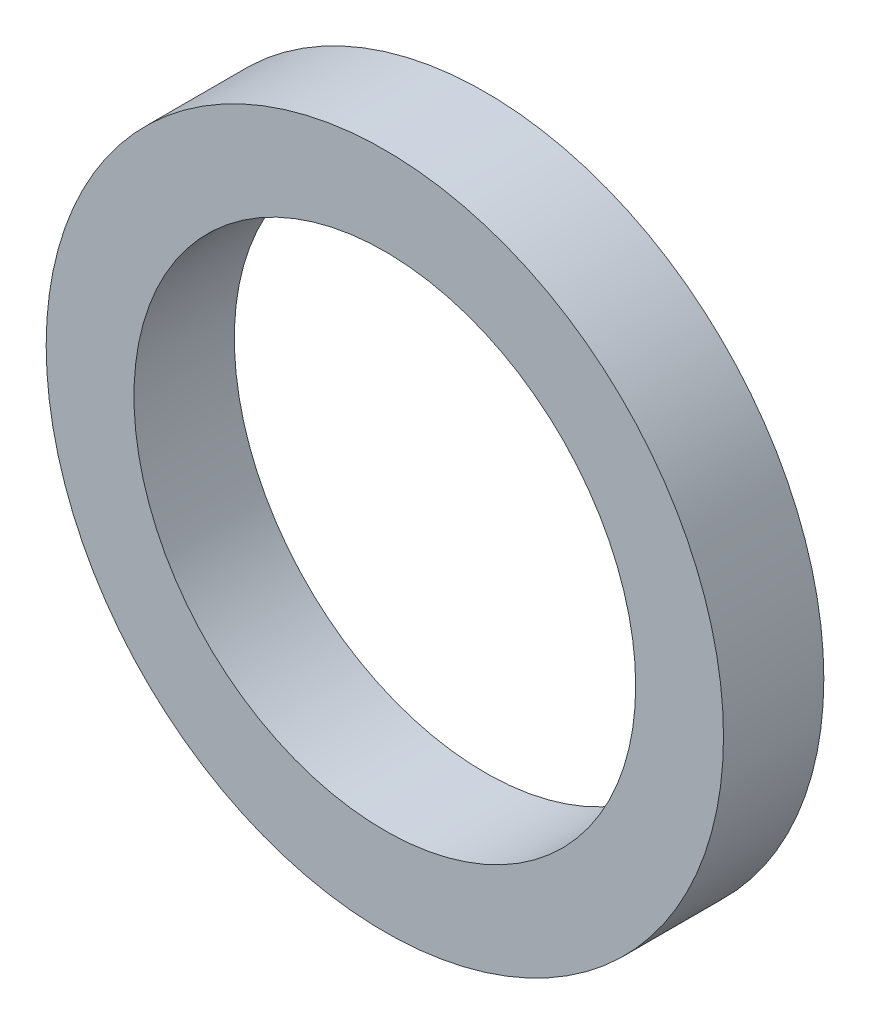
from build123d import *

# Parameters (mm, degrees)
SKETCH_1_R      = 13.5
SKETCH_1_R_2    = 10
EXTRUDE_1_DEPTH = 4


with BuildPart() as part:
    # 草图1 → 凸台-拉伸1 (new body)
    with BuildSketch(Plane.XY):
        Circle(SKETCH_1_R)
        Circle(SKETCH_1_R_2, mode=Mode.SUBTRACT)
    extrude(amount=EXTRUDE_1_DEPTH)


solid = part.part
